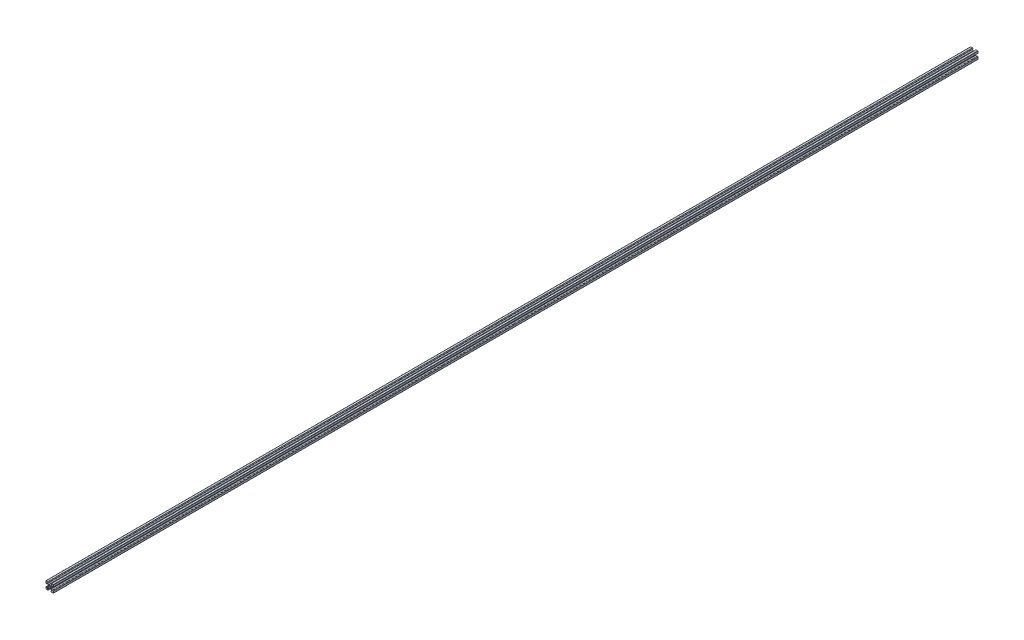
from build123d import *

# Parameters (mm, degrees)
SKETCH1_R           = 2.1
BOSS_EXTRUDE1_DEPTH = 2500


with BuildPart() as part:
    # Sketch1 → Boss-Extrude1 (new body)
    with BuildSketch(Plane.XY):
        with BuildLine():
            Line((4.58, -10), (9.5, -10))
            ThreePointArc((9.5, -10), (9.853553391, -9.853553391), (10, -9.5))
            Line((10, -9.5), (10, -4.58))
            Line((10, -4.58), (8.545, -3.125))
            Line((8.545, -3.125), (8.2, -3.125))
            Line((8.2, -3.125), (8.2, -5.5))
            Line((8.2, -5.5), (6.560660172, -5.5))
            Line((6.560660172, -5.5), (3.9, -2.839339828))
            Line((3.9, -2.839339828), (3.9, -0.21))
            Line((3.9, -0.21), (3.69, 0))
            Line((3.69, 0), (3.9, 0.21))
            Line((3.9, 0.21), (3.9, 2.839339828))
            Line((3.9, 2.839339828), (6.560660172, 5.5))
            Line((6.560660172, 5.5), (8.2, 5.5))
            Line((8.2, 5.5), (8.2, 3.125))
            Line((8.2, 3.125), (8.545, 3.125))
            Line((8.545, 3.125), (10, 4.58))
            Line((10, 4.58), (10, 9.5))
            ThreePointArc((10, 9.5), (9.853553391, 9.853553391), (9.5, 10))
            Line((9.5, 10), (4.58, 10))
            Line((4.58, 10), (3.125, 8.545))
            Line((3.125, 8.545), (3.125, 8.2))
            Line((3.125, 8.2), (5.5, 8.2))
            Line((5.5, 8.2), (5.5, 6.560660172))
            Line((5.5, 6.560660172), (2.839339828, 3.9))
            Line((2.839339828, 3.9), (0.21, 3.9))
            Line((0.21, 3.9), (0, 3.69))
            Line((0, 3.69), (-0.21, 3.9))
            Line((-0.21, 3.9), (-2.839339828, 3.9))
            Line((-2.839339828, 3.9), (-5.5, 6.560660172))
            Line((-5.5, 6.560660172), (-5.5, 8.2))
            Line((-5.5, 8.2), (-3.125, 8.2))
            Line((-3.125, 8.2), (-3.125, 8.545))
            Line((-3.125, 8.545), (-4.58, 10))
            Line((-4.58, 10), (-9.5, 10))
            ThreePointArc((-9.5, 10), (-9.853553391, 9.853553391), (-10, 9.5))
            Line((-10, 9.5), (-10, 4.58))
            Line((-10, 4.58), (-8.545, 3.125))
            Line((-8.545, 3.125), (-8.2, 3.125))
            Line((-8.2, 3.125), (-8.2, 5.5))
            Line((-8.2, 5.5), (-6.560660172, 5.5))
            Line((-6.560660172, 5.5), (-3.9, 2.839339828))
            Line((-3.9, 2.839339828), (-3.9, 0.21))
            Line((-3.9, 0.21), (-3.69, 0))
            Line((-3.69, 0), (-3.9, -0.21))
            Line((-3.9, -0.21), (-3.9, -2.839339828))
            Line((-3.9, -2.839339828), (-6.560660172, -5.5))
            Line((-6.560660172, -5.5), (-8.2, -5.5))
            Line((-8.2, -5.5), (-8.2, -3.125))
            Line((-8.2, -3.125), (-8.545, -3.125))
            Line((-8.545, -3.125), (-10, -4.58))
            Line((-10, -4.58), (-10, -9.5))
            ThreePointArc((-10, -9.5), (-9.853553391, -9.853553391), (-9.5, -10))
            Line((-9.5, -10), (-4.58, -10))
            Line((-4.58, -10), (-3.125, -8.545))
            Line((-3.125, -8.545), (-3.125, -8.2))
            Line((-3.125, -8.2), (-5.5, -8.2))
            Line((-5.5, -8.2), (-5.5, -6.560660172))
            Line((-5.5, -6.560660172), (-2.839339828, -3.9))
            Line((-2.839339828, -3.9), (-0.21, -3.9))
            Line((-0.21, -3.9), (0, -3.69))
            Line((0, -3.69), (0.21, -3.9))
            Line((0.21, -3.9), (2.839339828, -3.9))
            Line((2.839339828, -3.9), (5.5, -6.560660172))
            Line((5.5, -6.560660172), (5.5, -8.2))
            Line((5.5, -8.2), (3.125, -8.2))
            Line((3.125, -8.2), (3.125, -8.545))
            Line((3.125, -8.545), (4.58, -10))
        make_face()
        Circle(SKETCH1_R, mode=Mode.SUBTRACT)
    extrude(amount=BOSS_EXTRUDE1_DEPTH)


solid = part.part
